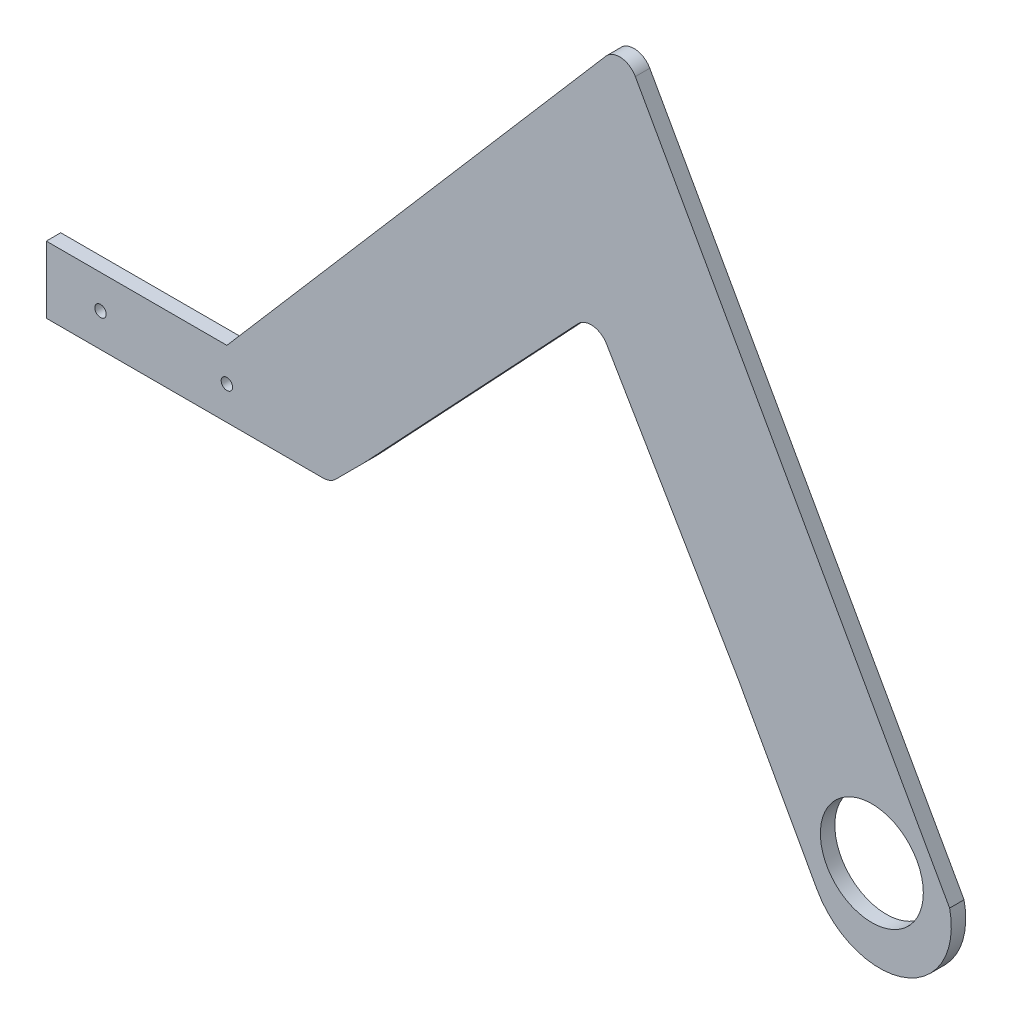
from build123d import *

# Parameters (mm, degrees)
CROQUIS1_R              = 1.58
CROQUIS1_R_2            = 14.25
SALIENTE_EXTRUIR1_DEPTH = 4


with BuildPart() as part:
    # Croquis1 → Saliente-Extruir1 (new body)
    with BuildSketch(Plane.XY):
        with BuildLine():
            Line((30.124466094, -7.785533906), (37.91, 0))
            Line((37.91, 0), (97.165453192, 63.015199165))
            ThreePointArc((97.165453192, 63.015199165), (101.36659613, 64.558696549), (105.120132173, 62.12087922))
            Line((105.120132173, 62.12087922), (141.58, 0))
            Line((141.58, 0), (153.799494633, -22.164589344))
            Line((153.799494633, -22.164589344), (155.71, -25.63))
            Line((155.71, -25.63), (163.352260057, -39.49207539))
            ThreePointArc((163.352260057, -39.49207539), (187.721004887, -48.471027794), (200.08, -25.63))
            Line((200.08, -25.63), (113.076169939, 130.225021029))
            ThreePointArc((113.076169939, 130.225021029), (109.214360618, 132.762403753), (104.922096847, 131.051160333))
            Line((104.922096847, 131.051160333), (0, 9.25))
            Line((0, 9.25), (-35, 9.25))
            Line((-35, 9.25), (-50, 9.25))
            Line((-50, 9.25), (-50, -9.25))
            Line((-50, -9.25), (-35, -9.25))
            Line((-35, -9.25), (0, -9.25))
            Line((0, -9.25), (26.588932188, -9.25))
            ThreePointArc((26.588932188, -9.25), (28.50234935, -8.869397663), (30.124466094, -7.785533906))
        make_face()
        with Locations((-35, 0)):
            Circle(CROQUIS1_R, mode=Mode.SUBTRACT)
        Circle(CROQUIS1_R, mode=Mode.SUBTRACT)
        with Locations((178.55, -25.63)):
            Circle(CROQUIS1_R_2, mode=Mode.SUBTRACT)
    extrude(amount=SALIENTE_EXTRUIR1_DEPTH)


solid = part.part
